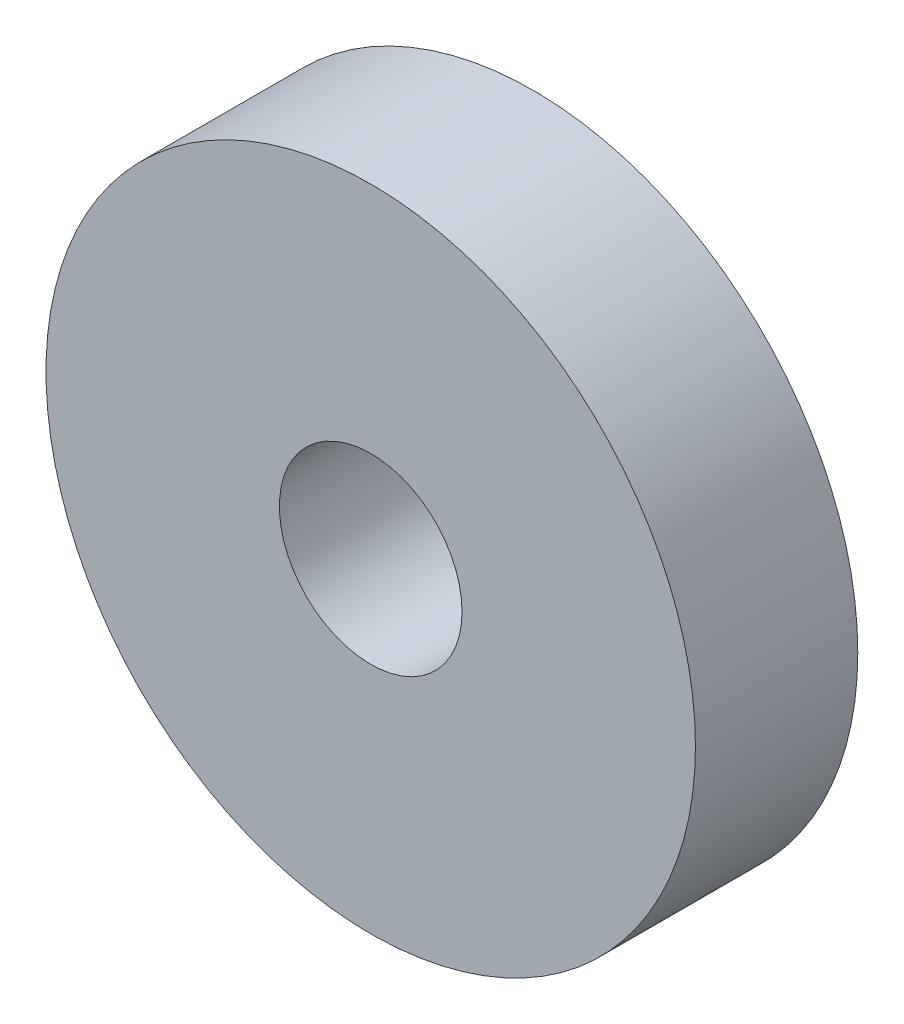
from build123d import *

# Parameters (mm, degrees)
SKETCH1_R           = 50.8
SKETCH1_R_2         = 14.2875
BOSS_EXTRUDE1_DEPTH = 25.4


with BuildPart() as part:
    # Sketch1 → Boss-Extrude1 (new body)
    with BuildSketch(Plane.XY):
        Circle(SKETCH1_R)
        Circle(SKETCH1_R_2, mode=Mode.SUBTRACT)
    extrude(amount=BOSS_EXTRUDE1_DEPTH)


solid = part.part
